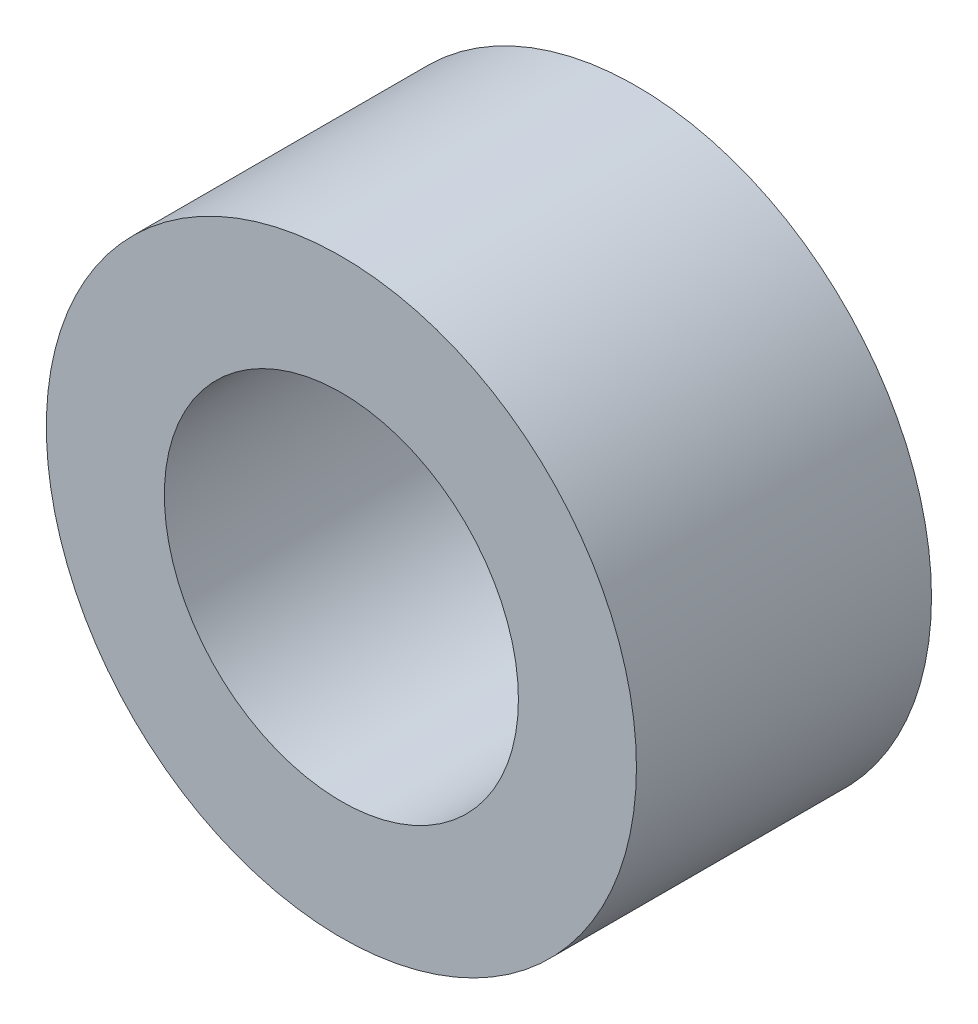
from build123d import *

# Parameters (mm, degrees)
CROQUIS1_R              = 5
CROQUIS1_R_2            = 3
SALIENTE_EXTRUIR1_DEPTH = 5


with BuildPart() as part:
    # Croquis1 → Saliente-Extruir1 (new body)
    with BuildSketch(Plane.XY):
        Circle(CROQUIS1_R)
        Circle(CROQUIS1_R_2, mode=Mode.SUBTRACT)
    extrude(amount=SALIENTE_EXTRUIR1_DEPTH)


solid = part.part
